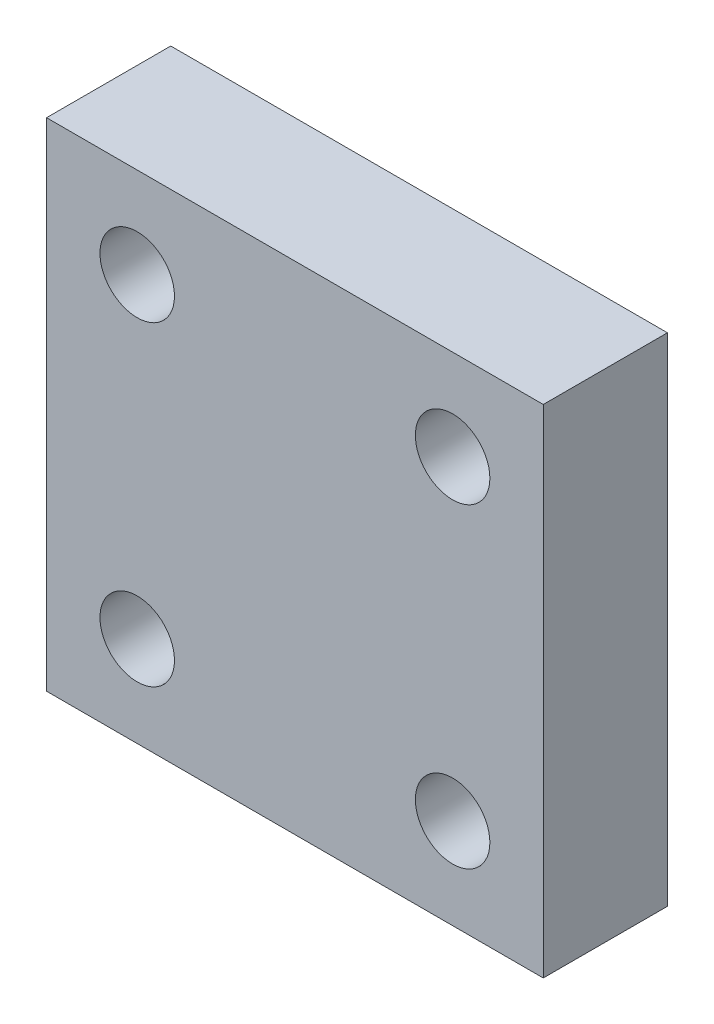
from build123d import *

# Parameters (mm, degrees)
SKETCH1_W           = 40
SKETCH1_H           = 40
BOSS_EXTRUDE1_DEPTH = 10
SKETCH2_R           = 1.32
CUT_EXTRUDE2_DEPTH  = 5
SKETCH5_R           = 3
CUT_EXTRUDE3_DEPTH  = 5


with BuildPart() as part:
    # Sketch1 → Boss-Extrude1 (new body)
    with BuildSketch(Plane.XY):
        with Locations((-20, -20)):
            Rectangle(SKETCH1_W, SKETCH1_H)
    extrude(amount=BOSS_EXTRUDE1_DEPTH)

    # Sketch2 → Cut-Extrude2 (cut)
    with BuildSketch(Plane.XY):
        with Locations((-35.87, -35.875)):
            Circle(SKETCH2_R)
        with Locations((-4.12, -35.875)):
            Circle(SKETCH2_R)
        with Locations((-4.12, -4.125)):
            Circle(SKETCH2_R)
        with Locations((-35.87, -4.125)):
            Circle(SKETCH2_R)
    extrude(amount=CUT_EXTRUDE2_DEPTH, mode=Mode.SUBTRACT)

    # Sketch5 → Cut-Extrude3 (cut)
    with BuildSketch(Plane.XY.offset(10)):
        with Locations((-32.7, -7.3)):
            Circle(SKETCH5_R)
        with Locations((-7.3, -7.3)):
            Circle(SKETCH5_R)
        with Locations((-7.3, -32.7)):
            Circle(SKETCH5_R)
        with Locations((-32.7, -32.7)):
            Circle(SKETCH5_R)
    extrude(amount=-CUT_EXTRUDE3_DEPTH, mode=Mode.SUBTRACT)


solid = part.part
